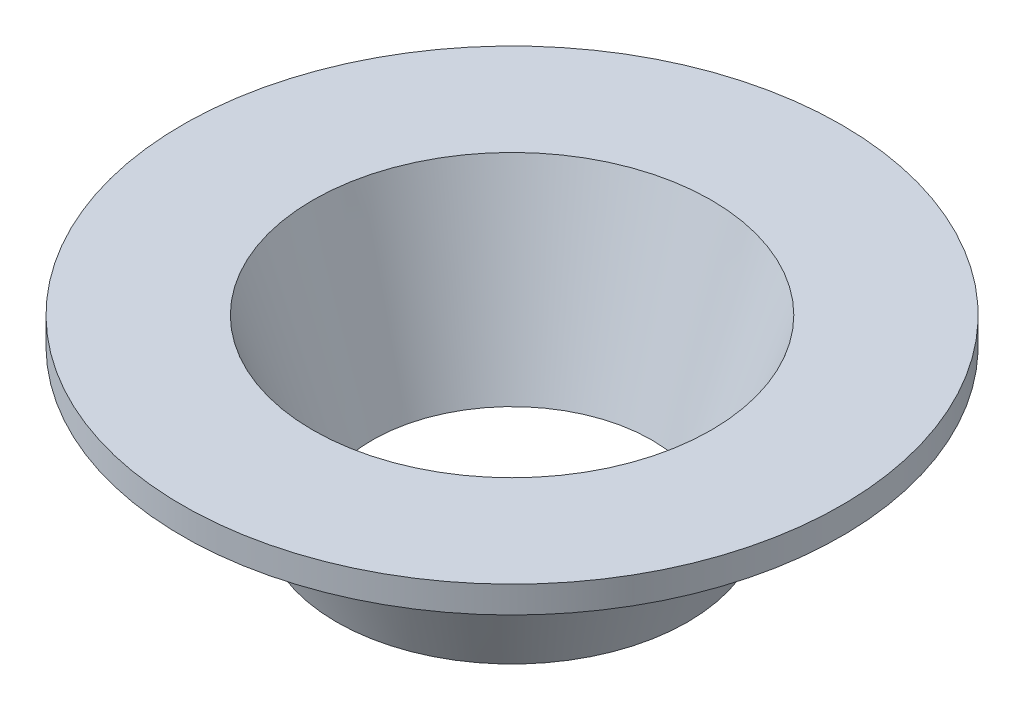
from build123d import *


with BuildPart() as part:
    # Sketch1 → Revolve1 (revolve)
    with BuildSketch(Plane.XY):
        Polygon((-2, 0), (-4, 0), (-7.15, 8.5), (-12.65, 8.5), (-12.65, 10), (-5.333333333, 10), align=None)
    revolve(axis=Axis((5.85, -1.308652139, 0), (0, 1, 0)))


solid = part.part
